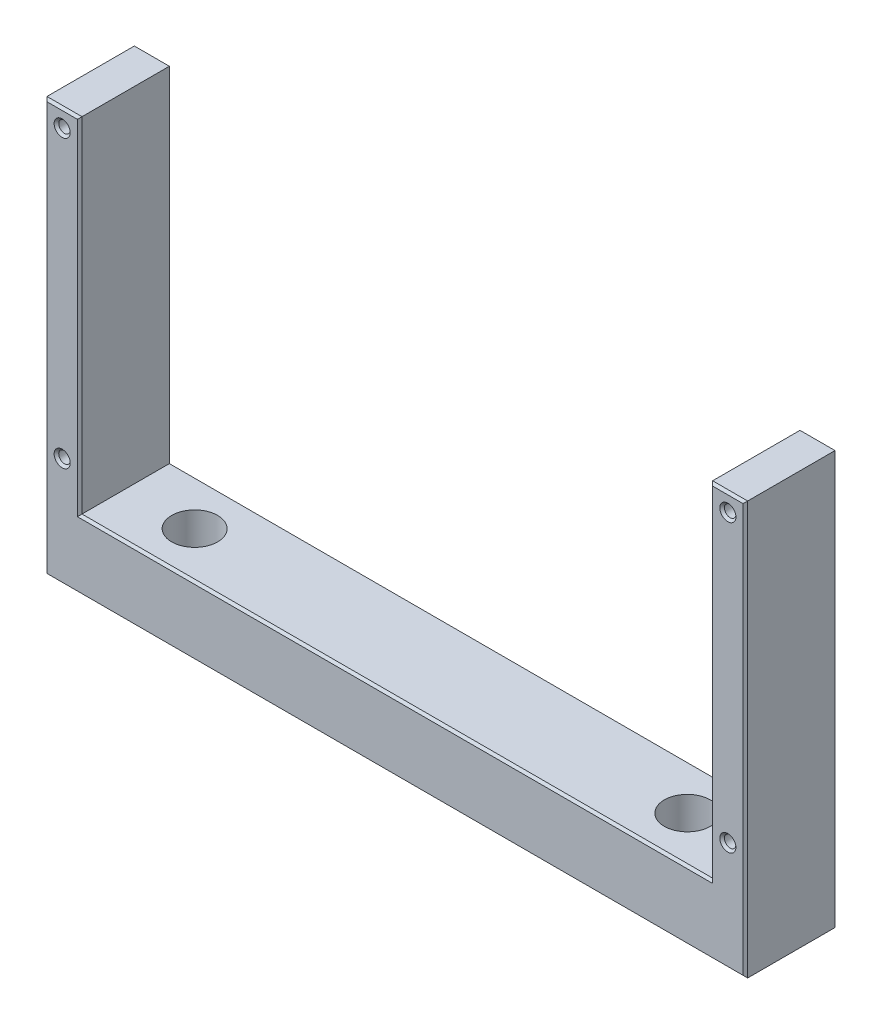
from build123d import *

# Parameters (mm, degrees)
BOSS_EXTRUDE1_DEPTH            = 20
M3X0_5_TAPPED_HOLE1_D          = 2.5
CHAMFER1_SIZE                  = 0.5
CBORE_FOR_M5_SHCS1_D           = 5.5
CBORE_FOR_M5_SHCS1_CBORE_D     = 10
CBORE_FOR_M5_SHCS1_CBORE_DEPTH = 10


with BuildPart() as part:
    # Sketch2 → Boss-Extrude1 (new body)
    with BuildSketch(Plane.XY):
        Polygon((-76.2, 34.925), (-68.58, 34.925), (-68.58, -39.925), (68.58, -39.925), (68.58, 34.925), (76.2, 34.925), (76.2, -54.925), (-76.2, -54.925), align=None)
    extrude(amount=BOSS_EXTRUDE1_DEPTH)

    # M3x0.5 Tapped Hole1 (through all)
    with Locations(Plane(origin=(0, 0, 0), x_dir=(-1, 0, 0), z_dir=(0, 0, -1))):
        with Locations((-72.39, -31.115), (-72.39, 31.115), (72.39, 31.115), (72.39, -31.115)):
            Hole(M3X0_5_TAPPED_HOLE1_D / 2)

    # Chamfer1
    chamfer1_edges = [part.edges().sort_by_distance(p)[0] for p in [
        (72.39, 34.925, 0),
        (76.2, -10, 0),
        (0, -54.925, 0),
        (-76.2, -10, 0),
        (76.2, -10, 20),
        (72.39, 34.925, 20),
        (68.58, -2.5, 20),
        (0, -39.925, 20),
        (-73.64, -31.115, 0),
        (-73.64, -31.115, 20),
        (-68.58, -2.5, 20),
        (-73.64, 31.115, 0),
        (-73.64, 31.115, 20),
        (-72.39, 34.925, 20),
        (71.14, 31.115, 0),
        (71.14, 31.115, 20),
        (71.14, -31.115, 0),
        (71.14, -31.115, 20),
        (-76.2, -10, 20),
        (-72.39, 34.925, 0),
        (0, -54.925, 20),
        (-68.58, -2.5, 0),
        (0, -39.925, 0),
        (68.58, -2.5, 0),
    ]]
    chamfer(chamfer1_edges, length=CHAMFER1_SIZE)

    # CBORE for M5 SHCS1 (through all)
    with Locations(Plane(origin=(-53.58, -39.925, 10), x_dir=(1, 0, 0), z_dir=(0, 1, 0))):
        with Locations((0, 0), (107.16, 0)):
            CounterBoreHole(CBORE_FOR_M5_SHCS1_D / 2, CBORE_FOR_M5_SHCS1_CBORE_D / 2, CBORE_FOR_M5_SHCS1_CBORE_DEPTH)


solid = part.part
